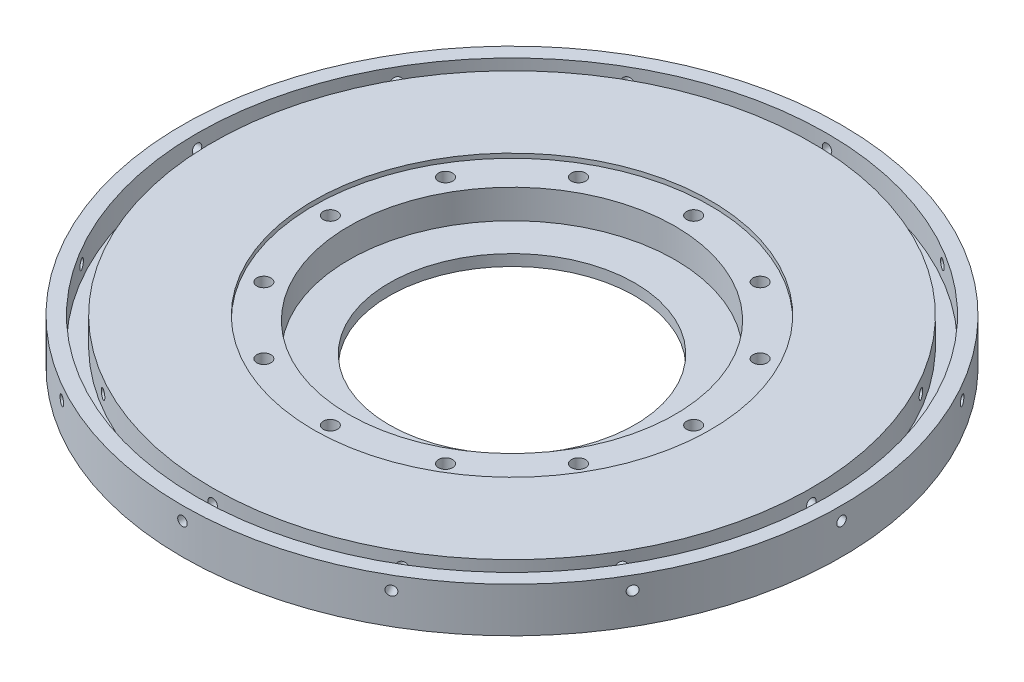
from build123d import *

# Parameters (mm, degrees)
SKETCH1_W           = 127.635
SKETCH1_H           = 127.635
BOSS_EXTRUDE1_DEPTH = 9.525
SKETCH13_R          = 93.6625
BOSS_EXTRUDE2_DEPTH = 12.7
SKETCH5_R           = 46.355
CUT_EXTRUDE1_DEPTH  = 9.525
SKETCH11_R          = 2.0193
CUT_EXTRUDE3_DEPTH  = 224.072165005
CIRPATTERN1_COUNT   = 12
SKETCH12_R          = 56.41975
CUT_EXTRUDE4_DEPTH  = 1.27
SKETCH16_R          = 89.535
SKETCH16_R_2        = 85.09
CUT_EXTRUDE5_DEPTH  = 7.62
SKETCH17_R          = 1.35255
CUT_EXTRUDE6_DEPTH  = 15.24
CIRPATTERN2_COUNT   = 12
SKETCH19_R          = 34.925
CUT_EXTRUDE7_DEPTH  = 87.63


with BuildPart() as part:
    # Sketch1 → Boss-Extrude1 (new body)
    with BuildSketch(Plane(origin=(0, 0, 0), x_dir=(1, 0, 0), z_dir=(0, 1, 0))):
        with Locations((63.8175, 63.8175)):
            Rectangle(SKETCH1_W, SKETCH1_H)
    extrude(amount=BOSS_EXTRUDE1_DEPTH)

    # Sketch13 → Boss-Extrude2 (add)
    with BuildSketch(Plane(origin=(0, 9.525, 0), x_dir=(1, 0, 0), z_dir=(0, 1, 0))):
        with Locations(Location((63.8175, 63.8175, 0), (0, 0, 270))):
            Circle(SKETCH13_R)
    extrude(amount=-BOSS_EXTRUDE2_DEPTH)

    # Sketch5 → Cut-Extrude1 (cut)
    with BuildSketch(Plane(origin=(0, 9.525, 0), x_dir=(1, 0, 0), z_dir=(0, 1, 0))):
        with Locations(Location((63.8175, 63.8175, 0), (0, 0, 270))):
            Circle(SKETCH5_R)
    extrude(amount=-CUT_EXTRUDE1_DEPTH, mode=Mode.SUBTRACT)

    # Sketch11 → Cut-Extrude3 (cut, through all)
    with BuildSketch(Plane(origin=(0, 9.525, 0), x_dir=(1, 0, 0), z_dir=(0, 1, 0))):
        with Locations(Location((63.8175, 115.443, 0), (0, 0, 270))):
            Circle(SKETCH11_R)
    cut_extrude3 = extrude(amount=-CUT_EXTRUDE3_DEPTH, mode=Mode.SUBTRACT)

    # CirPattern1: Cut-Extrude3 ×12 about axis
    cirpattern1_axis = Axis((63.8175, 0, -63.8175), (0, 1, 0))
    for i in range(1, CIRPATTERN1_COUNT):
        add(cut_extrude3.rotate(cirpattern1_axis, i * 360 / CIRPATTERN1_COUNT), mode=Mode.SUBTRACT)

    # Sketch12 → Cut-Extrude4 (cut)
    with BuildSketch(Plane(origin=(0, 9.525, 0), x_dir=(1, 0, 0), z_dir=(0, 1, 0))):
        with Locations(Location((63.8175, 63.8175, 0), (0, 0, 270))):
            Circle(SKETCH12_R)
    extrude(amount=-CUT_EXTRUDE4_DEPTH, mode=Mode.SUBTRACT)

    # Sketch16 → Cut-Extrude5 (cut)
    with BuildSketch(Plane(origin=(0, 9.525, 0), x_dir=(1, 0, 0), z_dir=(0, 1, 0))):
        with Locations(Location((63.8175, 63.8175, 0), (0, 0, 270))):
            Circle(SKETCH16_R)
        with Locations(Location((63.8175, 63.8175, 0), (0, 0, 270))):
            Circle(SKETCH16_R_2, mode=Mode.SUBTRACT)
    extrude(amount=-CUT_EXTRUDE5_DEPTH, mode=Mode.SUBTRACT)

    # Sketch17 → Cut-Extrude6 (cut)
    with BuildSketch(Plane.XY.offset(29.845)):
        with Locations((63.8175, 5.715)):
            Circle(SKETCH17_R)
    cut_extrude6 = extrude(amount=-CUT_EXTRUDE6_DEPTH, mode=Mode.SUBTRACT)

    # CirPattern2: Cut-Extrude6 ×12 about axis
    cirpattern2_axis = Axis((63.8175, 0, -63.8175), (0, 1, 0))
    for i in range(1, CIRPATTERN2_COUNT):
        add(cut_extrude6.rotate(cirpattern2_axis, i * 360 / CIRPATTERN2_COUNT), mode=Mode.SUBTRACT)

    # Sketch19 → Cut-Extrude7 (cut)
    with BuildSketch(Plane.XZ.offset(3.175)):
        with Locations(Location((63.8175, -63.8175, 0), (0, 0, 270))):
            Circle(SKETCH19_R)
    extrude(amount=-CUT_EXTRUDE7_DEPTH, mode=Mode.SUBTRACT)


solid = part.part
